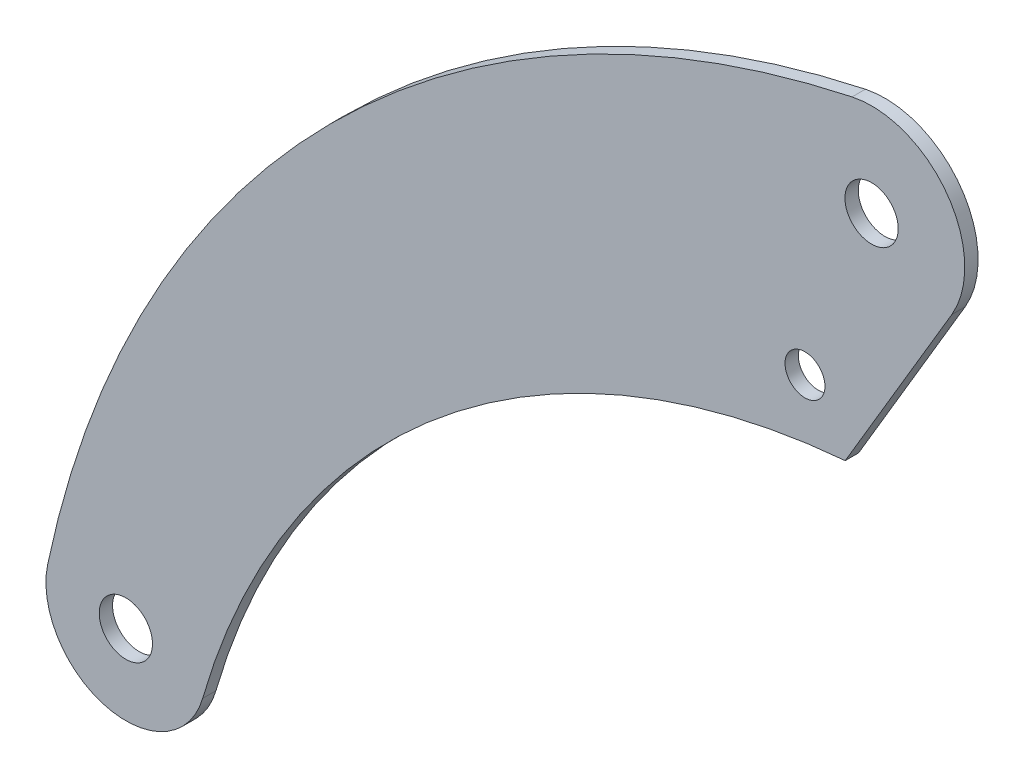
from build123d import *

# Parameters (mm, degrees)
SKETCH2_R           = 20
SKETCH2_R_2         = 15
BOSS_EXTRUDE1_DEPTH = 5


with BuildPart() as part:
    # Sketch2 → Boss-Extrude1 (new body, symmetric)
    with BuildSketch(Plane.XY):
        with BuildLine():
            Line((620.220407354, 514.313832679), (540.220407354, 379.313832679))
            ThreePointArc((540.220407354, 379.313832679), (237.335085129, 256.443922197), (57.658099017, -16.599506551))
            ThreePointArc((57.658099017, -16.599506551), (-14.483190404, -58.225743411), (-58.715737076, 12.347559255))
            ThreePointArc((-58.715737076, 12.347559255), (153.475240755, 404.94983662), (545.365415929, 618.45311497))
            ThreePointArc((545.365415929, 618.45311497), (616.839813073, 590.856280421), (620.220407354, 514.313832679))
        make_face()
        Circle(SKETCH2_R, mode=Mode.SUBTRACT)
        with Locations((560, 550)):
            Circle(SKETCH2_R, mode=Mode.SUBTRACT)
        with Locations((510, 420)):
            Circle(SKETCH2_R_2, mode=Mode.SUBTRACT)
    extrude(amount=BOSS_EXTRUDE1_DEPTH, both=True)


solid = part.part
